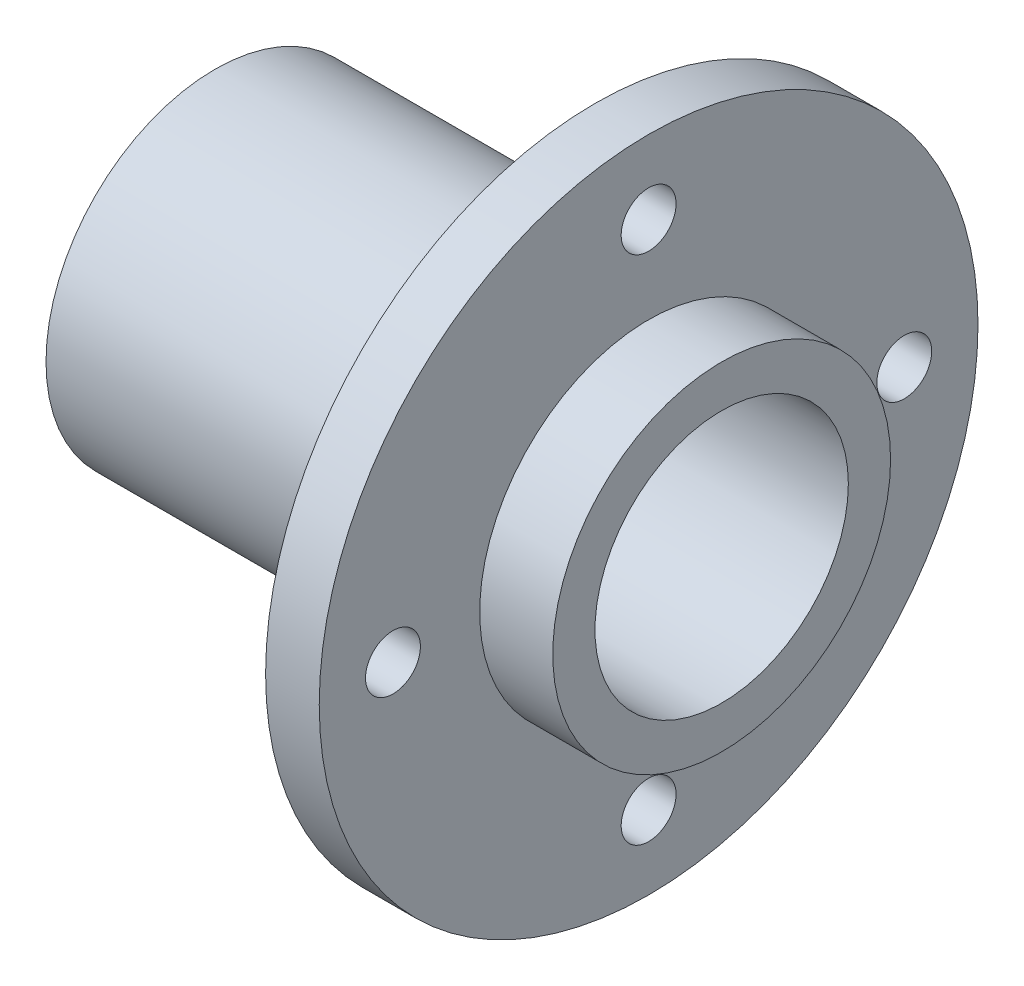
from build123d import *

# Parameters (mm, degrees)
SKETCH1_R           = 39
BOSS_EXTRUDE1_DEPTH = 6.35
SKETCH2_R           = 15
CUT_EXTRUDE1_DEPTH  = 6.35
SKETCH3_R           = 20
SKETCH3_R_2         = 15
BOSS_EXTRUDE2_DEPTH = 8.65
SKETCH4_R           = 20
SKETCH4_R_2         = 15
BOSS_EXTRUDE3_DEPTH = 45
SKETCH5_R           = 3.25
CUT_EXTRUDE2_DEPTH  = 45


with BuildPart() as part:
    # Sketch1 → Boss-Extrude1 (new body)
    with BuildSketch(Plane(origin=(0, 0, 0), x_dir=(0, 0, -1), z_dir=(1, 0, 0))):
        Circle(SKETCH1_R)
    extrude(amount=BOSS_EXTRUDE1_DEPTH)

    # Sketch2 → Cut-Extrude1 (cut)
    with BuildSketch(Plane(origin=(6.35, 0, 0), x_dir=(0, 0, -1), z_dir=(1, 0, 0))):
        Circle(SKETCH2_R)
    extrude(amount=-CUT_EXTRUDE1_DEPTH, mode=Mode.SUBTRACT)

    # Sketch3 → Boss-Extrude2 (add)
    with BuildSketch(Plane(origin=(6.35, 0, 0), x_dir=(0, 0, -1), z_dir=(1, 0, 0))):
        Circle(SKETCH3_R)
        Circle(SKETCH3_R_2, mode=Mode.SUBTRACT)
    extrude(amount=BOSS_EXTRUDE2_DEPTH)

    # Sketch4 → Boss-Extrude3 (add)
    with BuildSketch(Plane.ZY):
        Circle(SKETCH4_R)
        Circle(SKETCH4_R_2, mode=Mode.SUBTRACT)
    extrude(amount=BOSS_EXTRUDE3_DEPTH)

    # Sketch5 → Cut-Extrude2 (cut)
    with BuildSketch(Plane.ZY):
        with Locations((0, 30.27)):
            Circle(SKETCH5_R)
        with Locations((-30.27, 0)):
            Circle(SKETCH5_R)
        with Locations((30.27, 0)):
            Circle(SKETCH5_R)
        with Locations((0, -30.27)):
            Circle(SKETCH5_R)
    extrude(amount=-CUT_EXTRUDE2_DEPTH, mode=Mode.SUBTRACT)


solid = part.part
